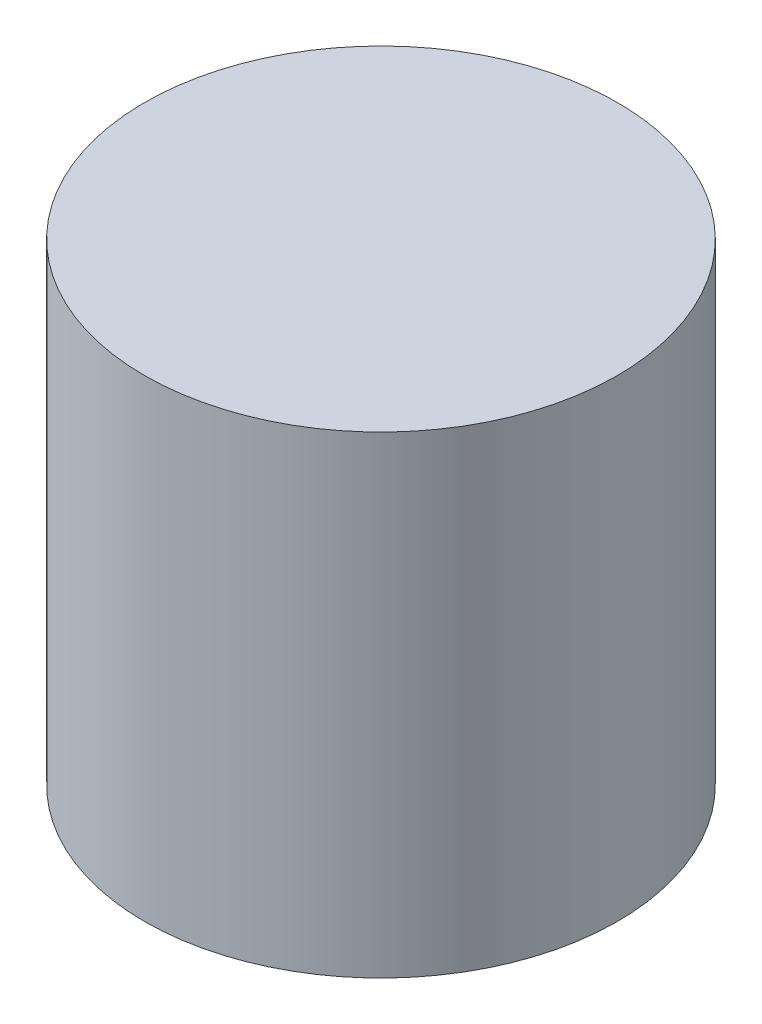
from build123d import *

# Parameters (mm, degrees)
SKETCH1_R           = 1.5
BOSS_EXTRUDE1_DEPTH = 3


with BuildPart() as part:
    # Sketch1 → Boss-Extrude1 (new body)
    with BuildSketch(Plane(origin=(0, 0, 0), x_dir=(1, 0, 0), z_dir=(0, 1, 0))):
        Circle(SKETCH1_R)
    extrude(amount=BOSS_EXTRUDE1_DEPTH)


solid = part.part
